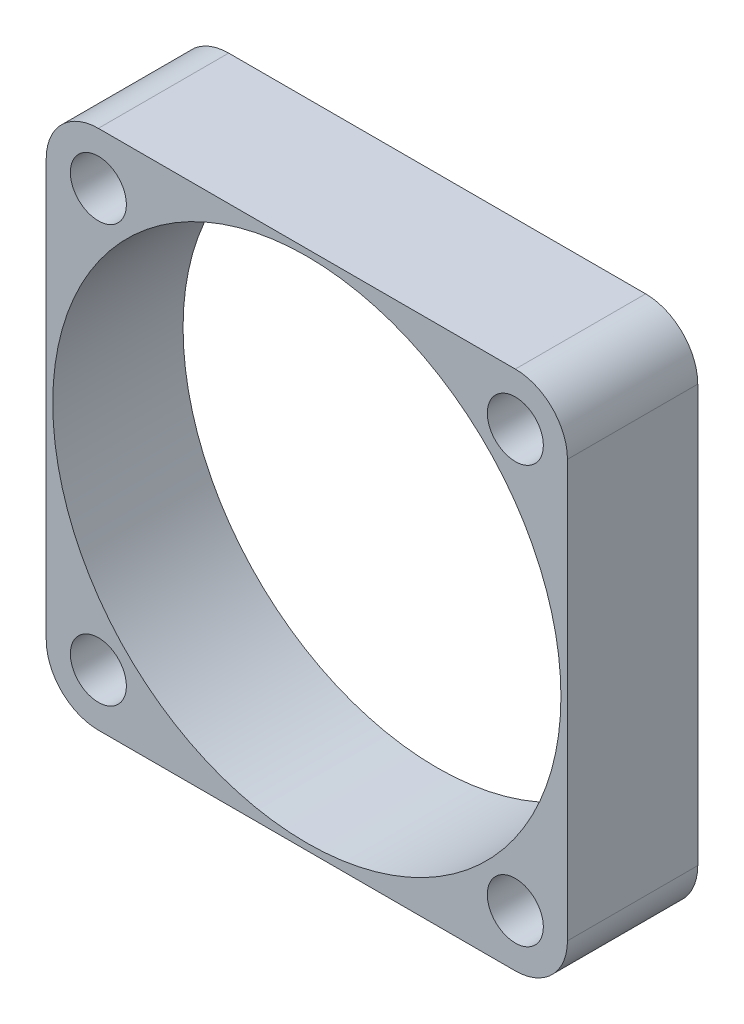
from build123d import *

# Parameters (mm, degrees)
EXTRUDE1_DEPTH     = 10
SKETCH2_R          = 19.5
CUT_EXTRUDE1_DEPTH = 20
SKETCH4_R          = 2.15
CUT_EXTRUDE2_DEPTH = 20


with BuildPart() as part:
    # Sketch1 → Extrude1 (new body)
    with BuildSketch(Plane.XY):
        with BuildLine():
            Line((4, 0), (36, 0))
            ThreePointArc((36, 0), (38.828427125, -1.171572875), (40, -4))
            Line((40, -4), (40, -36))
            ThreePointArc((40, -36), (38.828427125, -38.828427125), (36, -40))
            Line((36, -40), (4, -40))
            ThreePointArc((4, -40), (1.171572875, -38.828427125), (0, -36))
            Line((0, -36), (0, -4))
            ThreePointArc((0, -4), (1.171572875, -1.171572875), (4, 0))
        make_face()
    extrude(amount=EXTRUDE1_DEPTH)

    # Sketch2 → Cut-Extrude1 (cut)
    with BuildSketch(Plane.XY.offset(10)):
        with Locations((20, -20)):
            Circle(SKETCH2_R)
    extrude(amount=-CUT_EXTRUDE1_DEPTH, mode=Mode.SUBTRACT)

    # Sketch4 → Cut-Extrude2 (cut)
    with BuildSketch(Plane.XY.offset(10)):
        with Locations((36, -4)):
            Circle(SKETCH4_R)
        with Locations((4, -4)):
            Circle(SKETCH4_R)
        with Locations((4, -36)):
            Circle(SKETCH4_R)
        with Locations((36, -36)):
            Circle(SKETCH4_R)
    extrude(amount=-CUT_EXTRUDE2_DEPTH, mode=Mode.SUBTRACT)


solid = part.part
